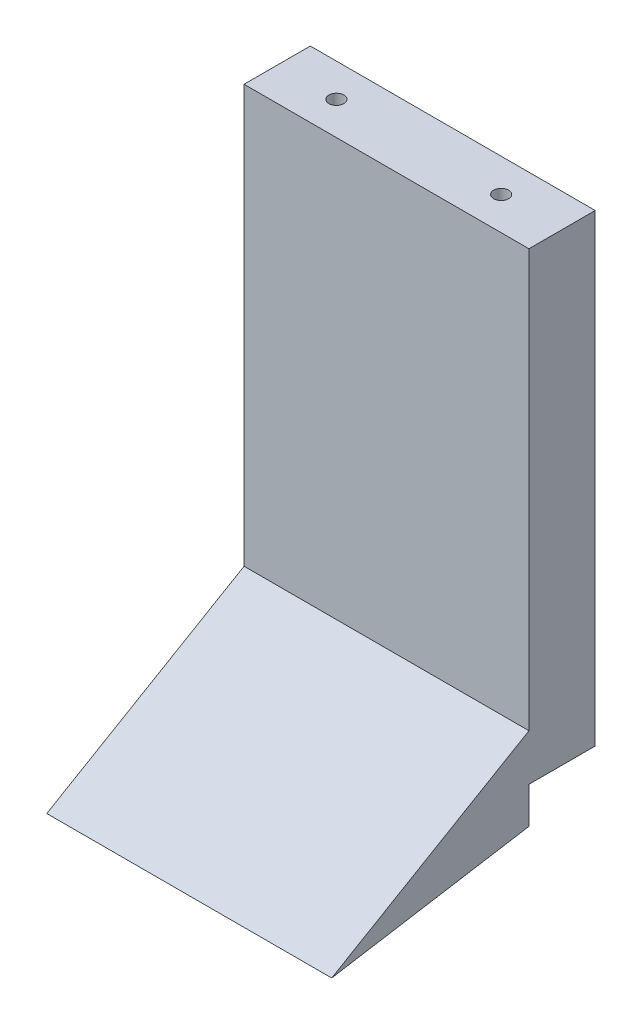
from build123d import *

# Parameters (mm, degrees)
SKETCH1_W                 = 43
SKETCH1_H                 = 10
BOSS_EXTRUDE1_DEPTH       = 70
BOSS_EXTRUDE3_DEPTH       = 43
SKETCH3_R                 = 0.685
CUT_EXTRUDE1_DEPTH        = 15
SKETCH4_R                 = 0.685
CUT_EXTRUDE2_DEPTH        = 15
F_4_40_TAPPED_HOLE1_D     = 2.2606
F_4_40_TAPPED_HOLE1_DEPTH = 7.6
F_4_40_TAPPED_HOLE1_TIP   = 0.679152758
F_4_40_TAPPED_HOLE2_D     = 2.2606
F_4_40_TAPPED_HOLE2_DEPTH = 7.6
F_4_40_TAPPED_HOLE2_TIP   = 0.679152758


with BuildPart() as part:
    # Sketch1 → Boss-Extrude1 (new body)
    with BuildSketch(Plane(origin=(0, 0, 0), x_dir=(1, 0, 0), z_dir=(0, 1, 0))):
        Rectangle(SKETCH1_W, SKETCH1_H)
    extrude(amount=BOSS_EXTRUDE1_DEPTH)

    # Sketch2 → Boss-Extrude3 (add)
    with BuildSketch(Plane(origin=(21.5, 0, 0), x_dir=(0, 0, -1), z_dir=(1, 0, 0))):
        Polygon((-5, 7), (-5, -5.5), (-34.772622472, -10.431034139), align=None)
    extrude(amount=-BOSS_EXTRUDE3_DEPTH)

    # Sketch3 → Cut-Extrude1 (cut)
    with BuildSketch(Plane.XZ):
        with Locations((-12.515, 0)):
            Circle(SKETCH3_R)
        with Locations((12.355, 0)):
            Circle(SKETCH3_R)
    extrude(amount=-CUT_EXTRUDE1_DEPTH, mode=Mode.SUBTRACT)

    # Sketch4 → Cut-Extrude2 (cut)
    with BuildSketch(Plane(origin=(0, 70, 0), x_dir=(1, 0, 0), z_dir=(0, 1, 0))):
        with Locations((-12.565, 0)):
            Circle(SKETCH4_R)
        with Locations((12.305, 0)):
            Circle(SKETCH4_R)
    extrude(amount=-CUT_EXTRUDE2_DEPTH, mode=Mode.SUBTRACT)

    # #4-40 Tapped Hole1
    with Locations(Plane(origin=(0, 70, 0), x_dir=(1, 0, 0), z_dir=(0, 1, 0))):
        with Locations((12.305, 0), (-12.565, 0)):
            Hole(F_4_40_TAPPED_HOLE1_D / 2, depth=F_4_40_TAPPED_HOLE1_DEPTH)
            with Locations((0, 0, -(F_4_40_TAPPED_HOLE1_DEPTH + F_4_40_TAPPED_HOLE1_TIP / 2))):  # 118° drill point
                Cone(0, F_4_40_TAPPED_HOLE1_D / 2, F_4_40_TAPPED_HOLE1_TIP, mode=Mode.SUBTRACT)

    # #4-40 Tapped Hole2
    with Locations(Plane(origin=(0, 0, 0), x_dir=(-1, 0, 0), z_dir=(0, -1, 0))):
        with Locations((-12.355, 0), (12.515, 0)):
            Hole(F_4_40_TAPPED_HOLE2_D / 2, depth=F_4_40_TAPPED_HOLE2_DEPTH)
            with Locations((0, 0, -(F_4_40_TAPPED_HOLE2_DEPTH + F_4_40_TAPPED_HOLE2_TIP / 2))):  # 118° drill point
                Cone(0, F_4_40_TAPPED_HOLE2_D / 2, F_4_40_TAPPED_HOLE2_TIP, mode=Mode.SUBTRACT)


solid = part.part
